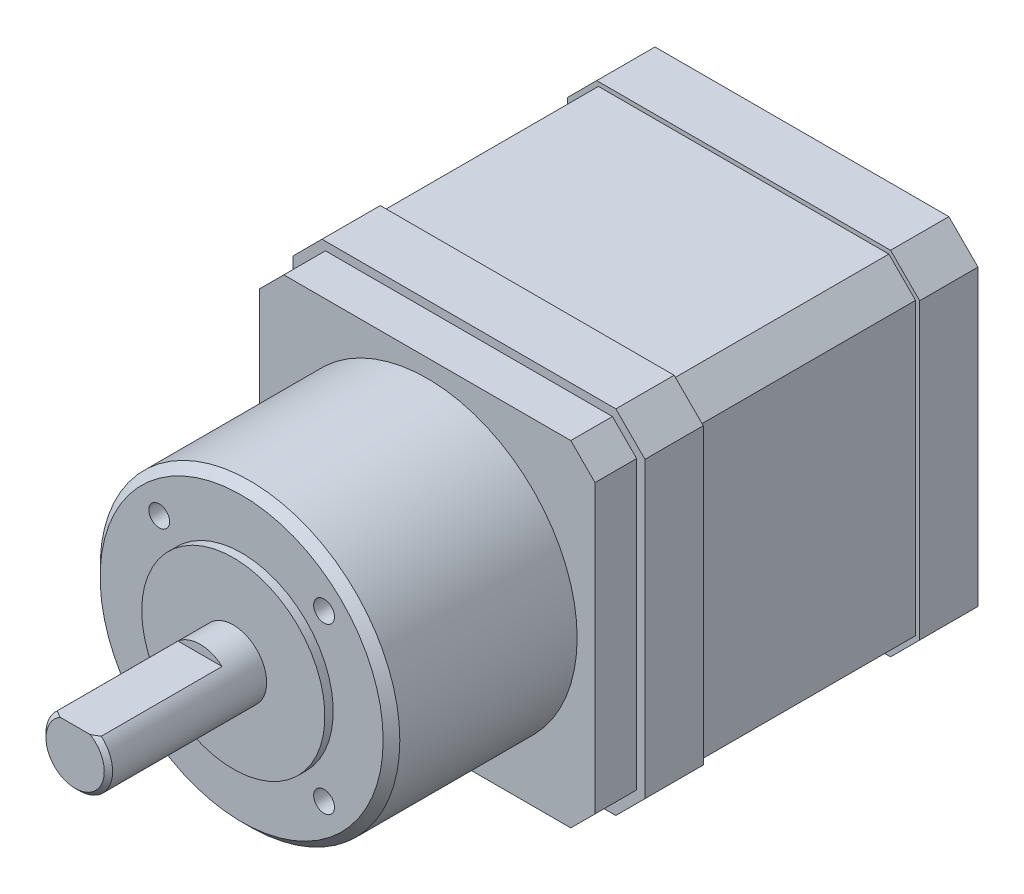
from build123d import *

# Parameters (mm, degrees)
SKIZZE1_W                       = 42.3
SKIZZE1_H                       = 42.3
AUFSATZ_LINEAR_AUSTRAGEN1_DEPTH = 40
FASE1_SIZE                      = 3.5
SCHNITT_LINEAR_AUSTRAGEN1_DEPTH = 15
FASE2_SIZE                      = 0.5
AUFSATZ_LINEAR_AUSTRAGEN2_DEPTH = 5
M3_GEWINDEBOHRUNG1_D            = 2.5
M3_GEWINDEBOHRUNG1_DEPTH        = 5
M3_GEWINDEBOHRUNG1_TIP          = 0.751075774
FASE3_SIZE                      = 1
SCHNITT_LINEAR_START            = -7
SCHNITT_LINEAR_AUSTRAGEN2_DEPTH = 26


with BuildPart() as part:
    # Skizze1 → Aufsatz-Linear austragen1 (new body)
    with BuildSketch(Plane.XY):
        Rectangle(SKIZZE1_W, SKIZZE1_H)
    extrude(amount=AUFSATZ_LINEAR_AUSTRAGEN1_DEPTH)

    # Skizze3 → Rotation1 (revolve)
    with BuildSketch(Plane(origin=(0, 0, 0), x_dir=(0, 0, -1), z_dir=(1, 0, 0))):
        Polygon((-40, 18), (-67.3, 18), (-67.3, 11), (-68.3, 11), (-68.3, 4), (-87.3, 4), (-87.3, 0), (-40, 0), align=None)
    revolve(axis=Axis((0, 0, 0), (0, 0, 1)))

    # Fase1
    fase1_edges = [part.edges().sort_by_distance(p)[0] for p in [
        (-21.15, 21.15, 20),
        (21.15, 21.15, 20),
        (21.15, -21.15, 20),
        (-21.15, -21.15, 20),
    ]]
    chamfer(fase1_edges, length=FASE1_SIZE)

    # Skizze4 → Schnitt-Linear austragen1 (cut)
    with BuildSketch(Plane.XY.offset(87.3)):
        with BuildLine():
            Line((-2.645751311, 3), (2.645751311, 3))
            ThreePointArc((2.645751311, 3), (0, 4), (-2.645751311, 3))
        make_face()
    extrude(amount=-SCHNITT_LINEAR_AUSTRAGEN1_DEPTH, mode=Mode.SUBTRACT)

    # Fase2
    fase2_edges = [part.edges().sort_by_distance(p)[0] for p in [
        (0, -4, 87.3),
    ]]
    chamfer(fase2_edges, length=FASE2_SIZE)

    # Skizze5 → Aufsatz-Linear austragen2 (add)
    with BuildSketch(Plane.XY.offset(40)):
        Polygon((20.15, 17.235786438), (17.235786438, 20.15), (-17.235786438, 20.15), (-20.15, 17.235786438), (-20.15, -17.235786438), (-17.235786438, -20.15), (17.235786438, -20.15), (20.15, -17.235786438), align=None)
    extrude(amount=AUFSATZ_LINEAR_AUSTRAGEN2_DEPTH)

    # M3 Gewindebohrung1
    with Locations(Plane.XY.offset(67.3)):
        with Locations((9.899494937, 9.899494937), (-9.899494937, 9.899494937), (-9.899494937, -9.899494937), (9.899494937, -9.899494937)):
            Hole(M3_GEWINDEBOHRUNG1_D / 2, depth=M3_GEWINDEBOHRUNG1_DEPTH)
            with Locations((0, 0, -(M3_GEWINDEBOHRUNG1_DEPTH + M3_GEWINDEBOHRUNG1_TIP / 2))):  # 118° drill point
                Cone(0, M3_GEWINDEBOHRUNG1_D / 2, M3_GEWINDEBOHRUNG1_TIP, mode=Mode.SUBTRACT)

    # Fase3
    fase3_edges = [part.edges().sort_by_distance(p)[0] for p in [
        (0, -18, 67.3),
    ]]
    chamfer(fase3_edges, length=FASE3_SIZE)

    # Skizze8 → Schnitt-Linear austragen2 (cut)
    with BuildSketch(Plane(origin=(0, 0, 0), x_dir=(-1, 0, 0), z_dir=(0, 0, -1)).offset(SCHNITT_LINEAR_START)):
        Polygon((17.65, 21.15), (-17.65, 21.15), (-21.15, 17.65), (-21.15, -17.65), (-17.65, -21.15), (17.65, -21.15), (21.15, -17.65), (21.15, 17.65), align=None)
        Polygon((17.442893219, 20.65), (-17.442893219, 20.65), (-20.65, 17.442893219), (-20.65, -17.442893219), (-17.442893219, -20.65), (17.442893219, -20.65), (20.65, -17.442893219), (20.65, 17.442893219), align=None, mode=Mode.SUBTRACT)
    extrude(amount=-SCHNITT_LINEAR_AUSTRAGEN2_DEPTH, mode=Mode.SUBTRACT)


solid = part.part
